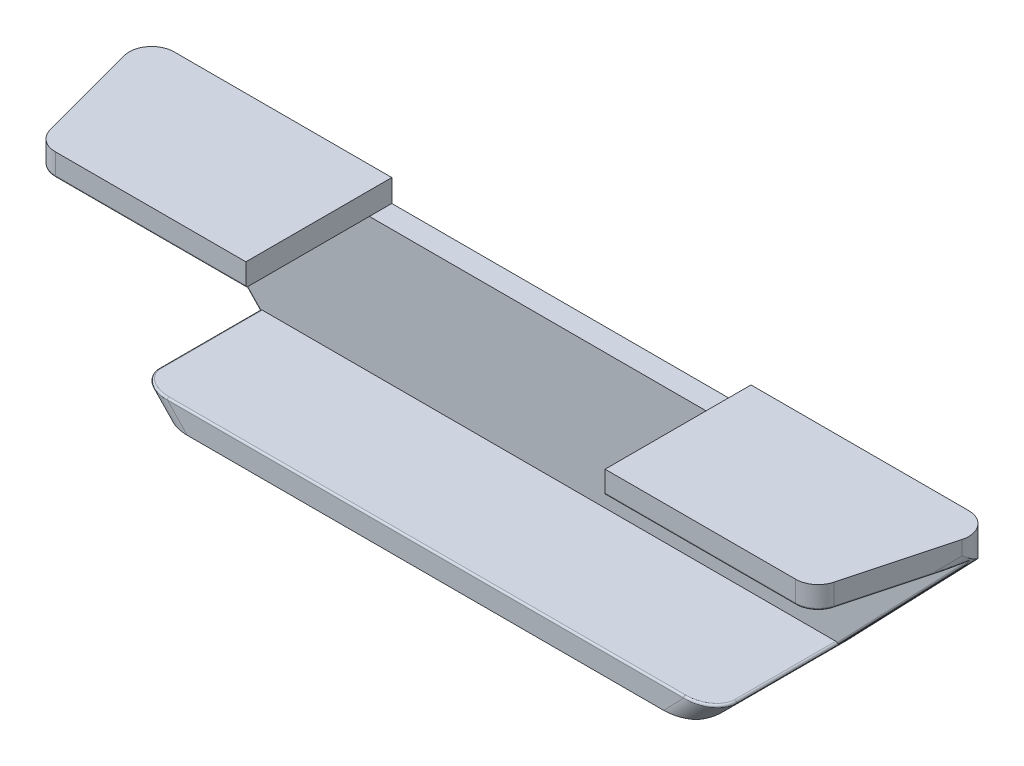
from build123d import *

# Parameters (mm, degrees)
SKETCH1_W           = 25.400000000000002
SKETCH1_H           = 25.400000000000002
SKETCH1_W_2         = 19.05
SKETCH1_H_2         = 19.05
BOSS_EXTRUDE1_DEPTH = 120.64999999999999
CUT_EXTRUDE1_DEPTH  = 126.8838452701537
CUT_EXTRUDE2_DEPTH  = 126.0099552285737
FILLET1_R           = 3.175
FILLET2_R           = 0.254
SKETCH4_R           = 1.7500000000000004
SKETCH4_R_2         = 1.7499999999999967
CUT_EXTRUDE3_DEPTH  = 124.59263330082443
CUT_EXTRUDE4_DEPTH  = 3.175


with BuildPart() as part:
    # Sketch1 → Boss-Extrude1 (new body)
    with BuildSketch(Plane(origin=(0, 0, 0), x_dir=(0, 0, -1), z_dir=(1, 0, 0))):
        with Locations((12.700000000000001, 12.700000000000001)):
            Rectangle(SKETCH1_W, SKETCH1_H)
        with Locations((12.700000000000001, 12.700000000000001)):
            Rectangle(SKETCH1_W_2, SKETCH1_H_2, mode=Mode.SUBTRACT)
    extrude(amount=BOSS_EXTRUDE1_DEPTH)

    # Sketch2 → Cut-Extrude1 (cut, through all)
    with BuildSketch(Plane(origin=(0, 25.400000000000002, 0), x_dir=(1, 0, 0), z_dir=(0, 1, 0))):
        Polygon((0, 25.400000000000002), (5.529801458797154, 4.762500000000003), (115.12019854120284, 4.762500000000003), (120.64999999999999, 25.400000000000002), (120.64999999999999, 0), (0, 0), align=None)
    extrude(amount=-CUT_EXTRUDE1_DEPTH, mode=Mode.SUBTRACT)

    # Sketch3 → Cut-Extrude2 (cut, through all)
    with BuildSketch(Plane.XY.offset(-4.762500000000003)):
        Polygon((0.8507386859688253, 22.225), (22.224999999999994, 0), (0, 0), (0, 23.109599800566922), align=None)
        Polygon((120.64999999999999, 23.109599800566873), (119.79926131403121, 22.225), (98.425, 0), (120.64999999999999, 0), align=None)
    extrude(amount=-CUT_EXTRUDE2_DEPTH, mode=Mode.SUBTRACT)

    # Fillet1
    fillet1_edges = [part.edges().sort_by_distance(p)[0] for p in [
        (5.529801458797154, 23.8125, -4.762500000000003),
        (115.12019854120284, 23.8125, -4.762500000000003),
        (0, 24.254799900283462, -25.400000000000002),
        (22.224999999999994, 0, -15.081250000000002),
        (0.4253693429843972, 22.667299900283474, -23.8125),
        (20.698267048997767, 1.5874999999999986, -4.762500000000003),
        (120.64999999999999, 24.254799900283437, -25.400000000000002),
        (120.2246306570156, 22.66729990028343, -23.812499999999993),
        (98.425, 0, -15.081250000000002),
        (99.95173295100223, 1.5875000000000006, -4.762500000000003),
    ]]
    fillet(fillet1_edges, radius=FILLET1_R)

    # Fillet2
    fillet2_edges = [part.edges().sort_by_distance(p)[0] for p in [
        (60.32500000000006, 3.1750000000000003, -4.762500000000003),
        (19.171534097995547, 3.1749999999999967, -15.08125),
        (20.71648513020903, 3.175, -5.522743575537653),
        (99.93351486978297, 3.175, -5.522743575532656),
        (117.10589841644389, 22.225, -12.173232822982987),
        (1.4544208351731096, 21.67540538374703, -22.225),
        (119.19557916482692, 21.675405383747048, -22.225),
        (3.544101583556124, 22.225, -12.1732328229829),
        (60.325, 22.225, -4.762500000000003),
        (6.033247108527673, 22.225, -5.418603144575334),
        (114.61675289147233, 22.225, -5.418603144575338),
        (1.596346512446972, 22.225, -19.71269813390116),
        (119.05365348755304, 22.225, -19.71269813390116),
        (10.51041950559126, 12.180844412027595, -22.225),
        (101.47846590200456, 3.1750000000000003, -15.08125),
        (110.13958049440878, 12.18084441202757, -22.225),
    ]]
    fillet(fillet2_edges, radius=FILLET2_R)

    # Sketch4 → Cut-Extrude3 (cut, through all)
    with BuildSketch(Plane.XY.offset(-22.225)):
        with Locations((22.22500000000001, 12.7)):
            Circle(SKETCH4_R)
        with Locations((98.42500000000001, 12.700000000000008)):
            Circle(SKETCH4_R_2)
    extrude(amount=-CUT_EXTRUDE3_DEPTH, mode=Mode.SUBTRACT)

    # Sketch5 → Cut-Extrude4 (cut)
    with BuildSketch(Plane(origin=(0, 25.400000000000002, 0), x_dir=(1, 0, 0), z_dir=(0, 1, 0))):
        Polygon((34.92500000000001, 25.40000000000001), (85.72500000000001, 25.400000000000027), (85.72500000000002, 4.7625000000000215), (34.92500000000001, 4.762500000000003), align=None)
    extrude(amount=-CUT_EXTRUDE4_DEPTH, mode=Mode.SUBTRACT)


solid = part.part
